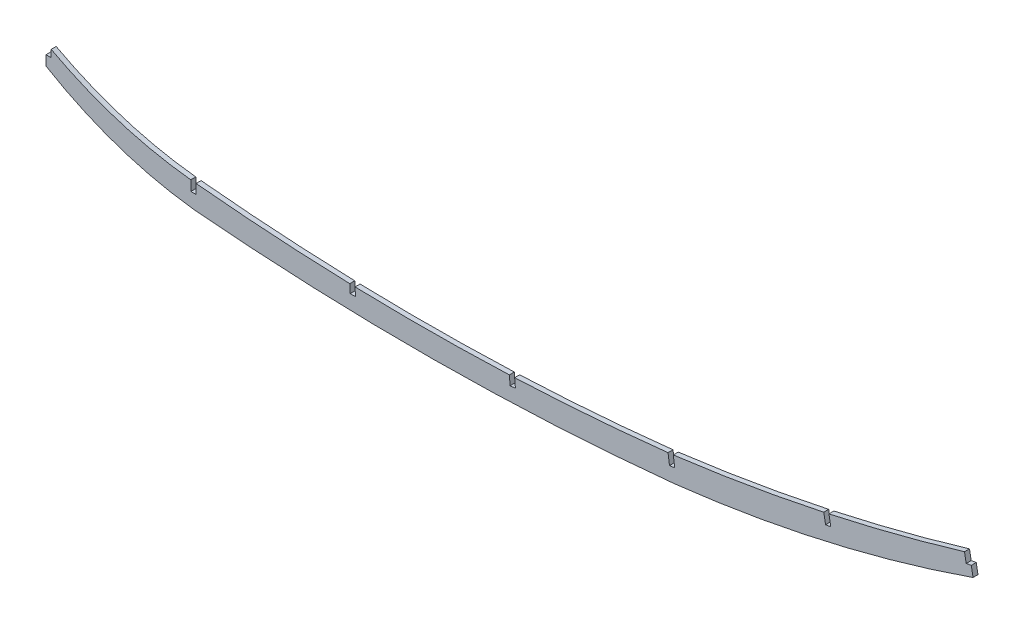
from build123d import *

# Parameters (mm, degrees)
BOSS_EXTRUDE1_DEPTH = 3.175
SKETCH3_W           = 3.3782
SKETCH3_H           = 9.116578424
CUT_EXTRUDE2_DEPTH  = 4.175


with BuildPart() as part:
    # Sketch2 → Boss-Extrude1 (new body)
    with BuildSketch(Plane.XY):
        with BuildLine():
            Line((0, -94.469447024), (0, -81.769447024))
            ThreePointArc((0, -81.769447024), (45.478698707, -101.330055673), (93.98, -111.257453101))
            ThreePointArc((93.98, -111.257453101), (246.131127604, -118.387559898), (398.184073829, -109.403930433))
            ThreePointArc((398.184073829, -109.403930433), (494.24795915, -93.166461028), (588.593285498, -68.858337449))
            Line((588.593285498, -68.858337449), (590.864339182, -81.353629169))
            ThreePointArc((590.864339182, -81.353629169), (496.73811025, -108.348158667), (400.203586987, -124.765753327))
            ThreePointArc((400.203586987, -124.765753327), (247.132802315, -132.883361709), (93.98, -126.497453101))
            ThreePointArc((93.98, -126.497453101), (45.293757409, -115.460746442), (0, -94.469447024))
        make_face()
    extrude(amount=-BOSS_EXTRUDE1_DEPTH)

    # Sketch3 → Cut-Extrude2 (cut, through all)
    with BuildSketch(Plane.XY):
        Polygon((0, -81.823651503), (0, -88.181271503), (3.302, -88.181271503), (3.302, -81.823651503), (3.302, -80.849253243), (0, -80.849253243), align=None)
        with Locations((93.98, -112.972963904)):
            Rectangle(SKETCH3_W, SKETCH3_H)
        Polygon((193.849633474, -123.151114373), (197.224876239, -123.009793743), (196.926348208, -115.879875231), (193.551105443, -116.021195861), align=None)
        Polygon((397.375099539, -116.299780406), (400.723885221, -115.854954941), (399.211318768, -104.467880056), (395.862533086, -104.912705522), align=None)
        Polygon((295.823280702, -123.008827736), (299.189034058, -122.719104443), (298.52739573, -115.032765525), (295.161642374, -115.322488818), align=None)
        Polygon((586.515324681, -75.768921214), (589.838721446, -75.162893837), (588.533193274, -68.003500927), (585.209796509, -68.609528304), align=None)
        Polygon((496.875793957, -99.221011682), (500.199190722, -98.614984306), (498.73195058, -90.568778264), (495.408553815, -91.174805641), align=None)
    extrude(amount=-CUT_EXTRUDE2_DEPTH, mode=Mode.SUBTRACT)


solid = part.part
